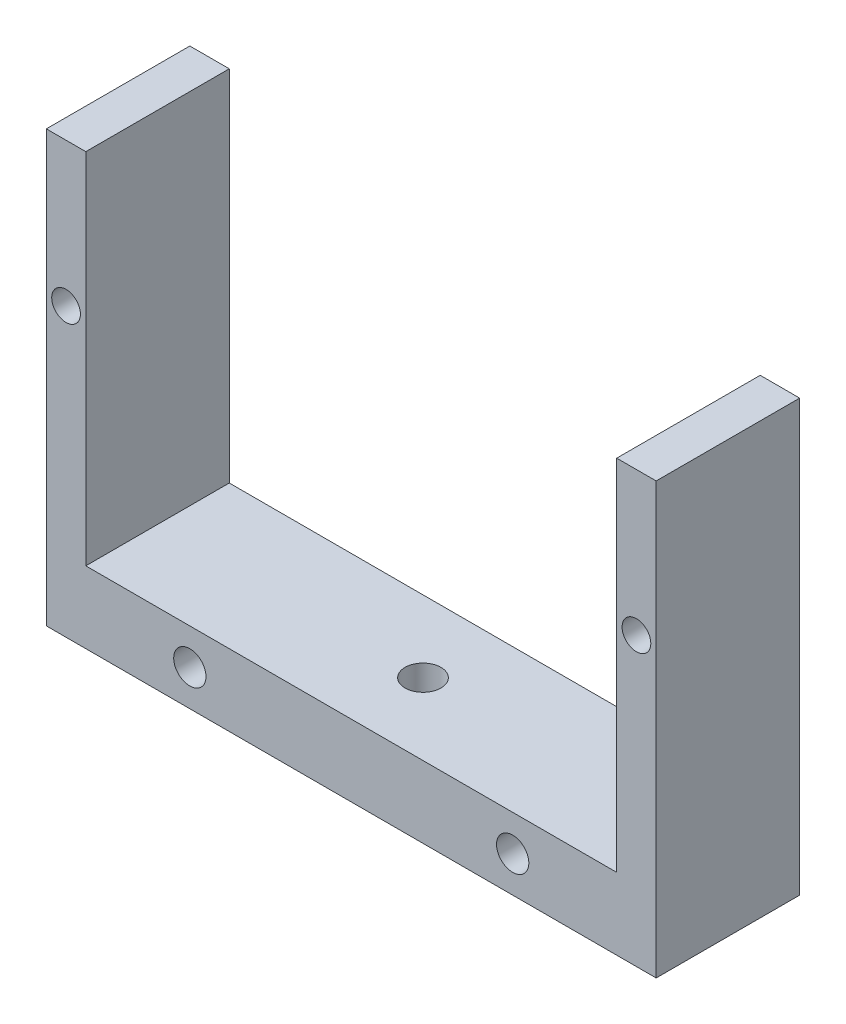
from build123d import *

# Parameters (mm, degrees)
BOSS_EXTRUDE1_DEPTH = 20
SKETCH2_R           = 2.25
CUT_EXTRUDE1_DEPTH  = 20
CUT_EXTRUDE2_REACH  = 22
SKETCH3_R           = 2
CUT_EXTRUDE3_REACH  = 12
SKETCH4_R           = 2.5


with BuildPart() as part:
    # Sketch1 → Boss-Extrude1 (new body)
    with BuildSketch(Plane.XY):
        Polygon((-58.140719223, -46.171804232), (26.859280777, -46.171804232), (26.859280777, 13.828195768), (21.359280777, 13.828195768), (21.359280777, -36.171804232), (-52.640719223, -36.171804232), (-52.640719223, 13.828195768), (-58.140719223, 13.828195768), align=None)
    extrude(amount=BOSS_EXTRUDE1_DEPTH)

    # Sketch2 → Cut-Extrude1 (cut)
    with BuildSketch(Plane(origin=(0, 0, 0), x_dir=(-1, 0, 0), z_dir=(0, 0, -1))):
        with Locations((-6.859280777, -41.171804232)):
            Circle(SKETCH2_R)
        with Locations((38.140719223, -41.171804232)):
            Circle(SKETCH2_R)
    extrude(amount=-CUT_EXTRUDE1_DEPTH, mode=Mode.SUBTRACT)

    # Sketch3 → Cut-Extrude2 (cut, up to next)
    with BuildSketch(Plane.XY.offset(20), mode=Mode.PRIVATE) as cut_extrude2_sk1:
        with Locations((-55.390719223, -6.171804232)):
            Circle(SKETCH3_R)
    cut_extrude2_tool1 = extrude(cut_extrude2_sk1.sketch, amount=-CUT_EXTRUDE2_REACH, mode=Mode.PRIVATE) & part.part
    add(cut_extrude2_tool1.solids().sort_by_distance((-55.390719, -6.171804, 20))[0], mode=Mode.SUBTRACT)
    # Sketch3 → Cut-Extrude2 (cut, up to next)
    with BuildSketch(Plane.XY.offset(20), mode=Mode.PRIVATE) as cut_extrude2_sk2:
        with Locations((24.109280777, -6.171804232)):
            Circle(SKETCH3_R)
    cut_extrude2_tool2 = extrude(cut_extrude2_sk2.sketch, amount=-CUT_EXTRUDE2_REACH, mode=Mode.PRIVATE) & part.part
    add(cut_extrude2_tool2.solids().sort_by_distance((24.109281, -6.171804, 20))[0], mode=Mode.SUBTRACT)

    # Sketch4 → Cut-Extrude3 (cut, up to next)
    with BuildSketch(Plane(origin=(0, -36.171804232, 0), x_dir=(1, 0, 0), z_dir=(0, 1, 0)), mode=Mode.PRIVATE) as cut_extrude3_sk1:
        with Locations((-15.640719223, -10)):
            Circle(SKETCH4_R)
    cut_extrude3_tool1 = extrude(cut_extrude3_sk1.sketch, amount=-CUT_EXTRUDE3_REACH, mode=Mode.PRIVATE) & part.part
    add(cut_extrude3_tool1.solids().sort_by_distance((-15.640719, -36.171804, 10))[0], mode=Mode.SUBTRACT)


solid = part.part
